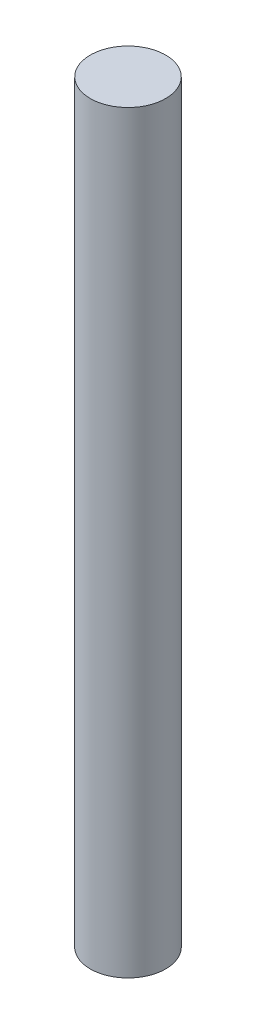
from build123d import *

# Parameters (mm, degrees)
SKETCH1_R           = 2.5
BOSS_EXTRUDE1_DEPTH = 50


with BuildPart() as part:
    # Sketch1 → Boss-Extrude1 (new body)
    with BuildSketch(Plane(origin=(0, 0, 0), x_dir=(1, 0, 0), z_dir=(0, 1, 0))):
        Circle(SKETCH1_R)
    extrude(amount=BOSS_EXTRUDE1_DEPTH)


solid = part.part
